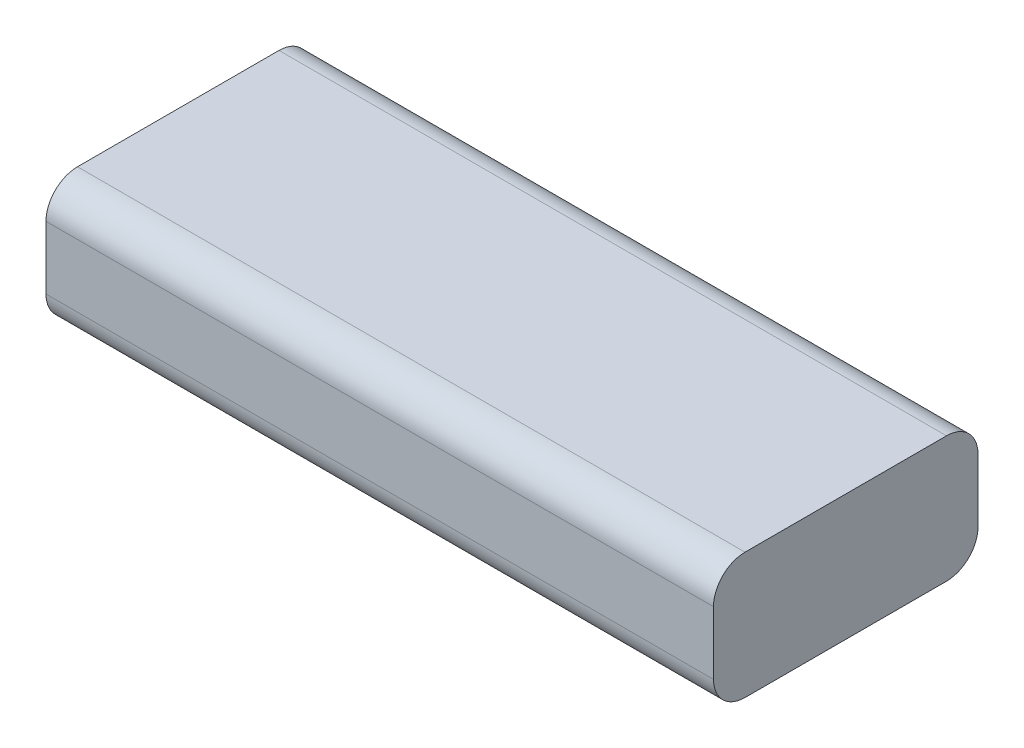
from build123d import *

# Parameters (mm, degrees)
SKETCH_1_W      = 106
SKETCH_1_H      = 42
EXTRUDE_1_DEPTH = 20
FILLET_1_R      = 5


with BuildPart() as part:
    # 草图1 → 凸台-拉伸1 (new body)
    with BuildSketch(Plane(origin=(0, 0, 0), x_dir=(1, 0, 0), z_dir=(0, 1, 0))):
        with Locations((53, 21)):
            Rectangle(SKETCH_1_W, SKETCH_1_H)
    extrude(amount=EXTRUDE_1_DEPTH)

    # 圆角1
    fillet_1_edges = [part.edges().sort_by_distance(p)[0] for p in [
        (53, 20, -42),
        (53, 0, -42),
        (53, 0, 0),
        (53, 20, 0),
    ]]
    fillet(fillet_1_edges, radius=FILLET_1_R)


solid = part.part
